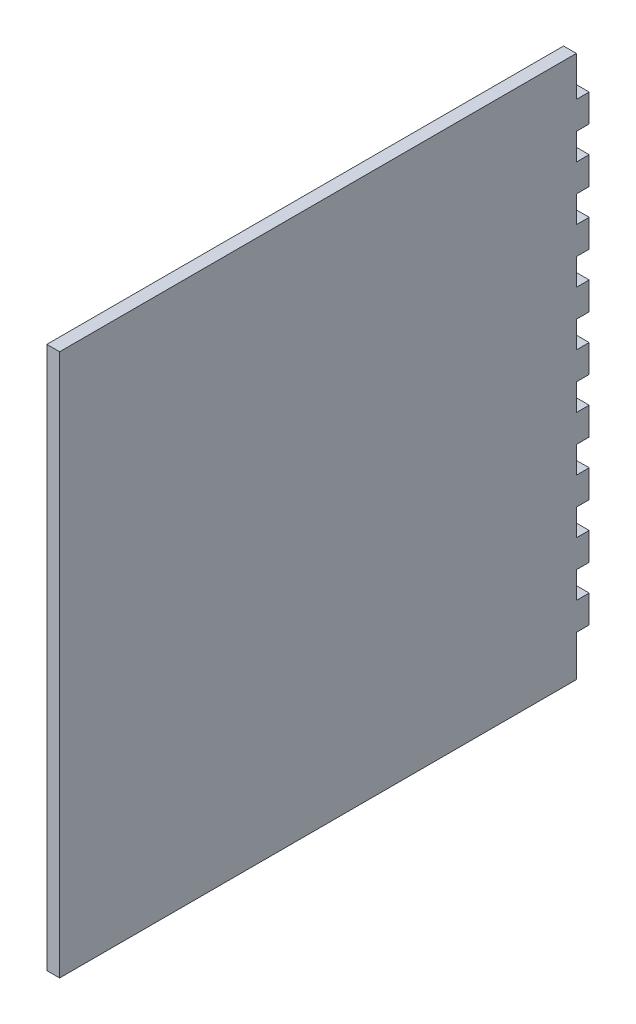
from build123d import *

# Parameters (mm, degrees)
BOSS_EXTRUDE1_DEPTH = 2.9972


with BuildPart() as part:
    # Sketch1 → Boss-Extrude1 (new body)
    with BuildSketch(Plane(origin=(0, 0, 0), x_dir=(0, 0, -1), z_dir=(1, 0, 0))):
        Polygon((121.0056, 0), (121.0056, -9.3345), (124.0028, -9.3345), (124.0028, -15.8115), (121.0056, -15.8115), (121.0056, -22.0345), (124.0028, -22.0345), (124.0028, -28.5115), (121.0056, -28.5115), (121.0056, -34.7345), (124.0028, -34.7345), (124.0028, -41.2115), (121.0056, -41.2115), (121.0056, -47.4345), (124.0028, -47.4345), (124.0028, -53.9115), (121.0056, -53.9115), (121.0056, -60.1345), (124.0028, -60.1345), (124.0028, -66.6115), (121.0056, -66.6115), (121.0056, -72.8345), (124.0028, -72.8345), (124.0028, -79.3115), (121.0056, -79.3115), (121.0056, -85.5345), (124.0028, -85.5345), (124.0028, -92.0115), (121.0056, -92.0115), (121.0056, -98.2345), (124.0028, -98.2345), (124.0028, -104.7115), (121.0056, -104.7115), (121.0056, -110.9345), (124.0028, -110.9345), (124.0028, -117.4115), (121.0056, -117.4115), (121.0056, -127), (0, -127), (0, 0), align=None)
    extrude(amount=BOSS_EXTRUDE1_DEPTH)


solid = part.part
